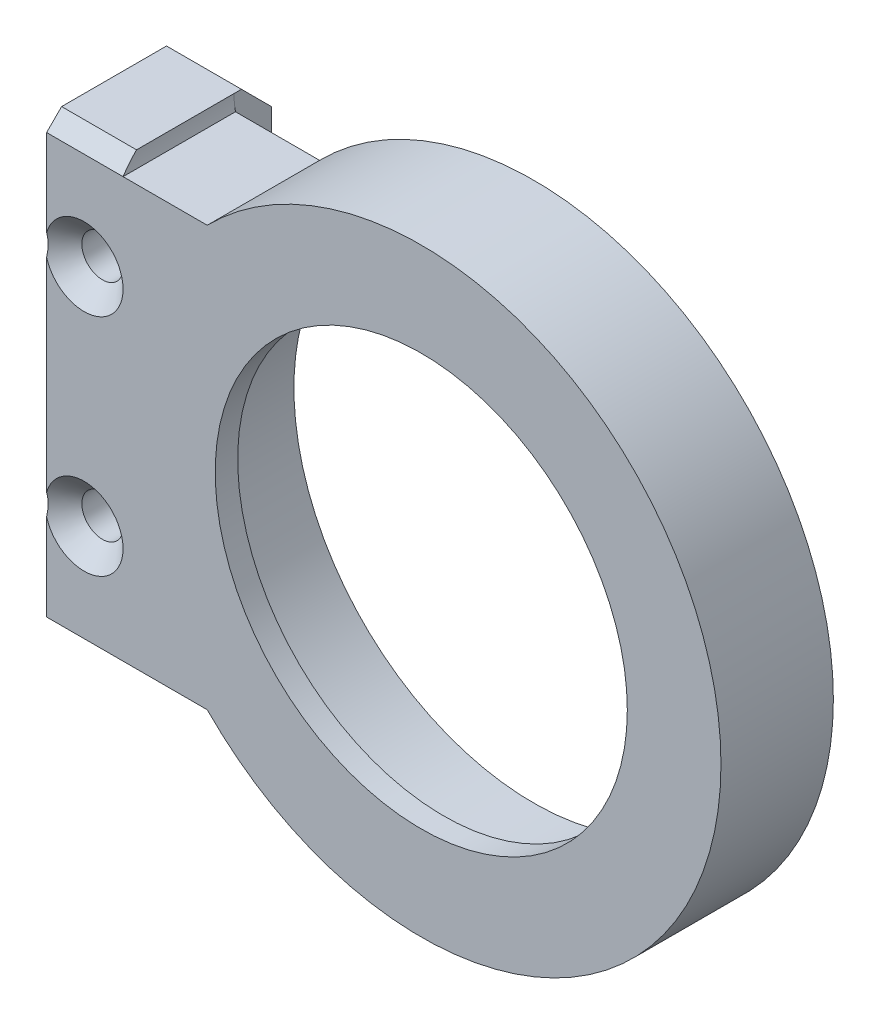
from build123d import *

# Parameters (mm, degrees)
SKETCH1_W                                       = 80
SKETCH1_H                                       = 80
BOSS_EXTRUDE1_DEPTH                             = 15
SKETCH2_R                                       = 32
CUT_EXTRUDE2_DEPTH                              = 16
SKETCH3_R                                       = 32
SKETCH3_R_2                                     = 27.5
BOSS_EXTRUDE2_DEPTH                             = 3
FILLET1_R                                       = 10
SKETCH5_W                                       = 10
SKETCH5_H                                       = 60
BOSS_EXTRUDE3_DEPTH                             = 20
SKETCH6_R                                       = 2.5
CUT_EXTRUDE3_DEPTH                              = 21
CHAMFER1_SIZE                                   = 2
CSK_FOR_M5_FLAT_HEAD_MACHINE_SCREW2_D           = 5.5
CSK_FOR_M5_FLAT_HEAD_MACHINE_SCREW2_CSINK_D     = 10.4
CSK_FOR_M5_FLAT_HEAD_MACHINE_SCREW2_CSINK_ANGLE = 90
CHAMFER2_SIZE                                   = 4
SKETCH11_R                                      = 15
CUT_EXTRUDE4_DEPTH                              = 2
CUT_EXTRUDE7_DEPTH                              = 21


with BuildPart() as part:
    # Sketch1 → Boss-Extrude1 (new body)
    with BuildSketch(Plane.XY):
        with Locations((40, 40)):
            Rectangle(SKETCH1_W, SKETCH1_H)
    extrude(amount=BOSS_EXTRUDE1_DEPTH)

    # Sketch2 → Cut-Extrude2 (cut, through all)
    with BuildSketch(Plane.XY.offset(15)):
        with Locations((40, 40)):
            Circle(SKETCH2_R)
    extrude(amount=-CUT_EXTRUDE2_DEPTH, mode=Mode.SUBTRACT)

    # Sketch3 → Boss-Extrude2 (add)
    with BuildSketch(Plane.XY.offset(15)):
        with Locations((40, 40)):
            Circle(SKETCH3_R)
        with Locations((40, 40)):
            Circle(SKETCH3_R_2, mode=Mode.SUBTRACT)
    extrude(amount=-BOSS_EXTRUDE2_DEPTH)

    # Fillet1
    fillet1_edges = [part.edges().sort_by_distance(p)[0] for p in [
        (0, 80, 7.5),
        (80, 80, 7.5),
        (80, 0, 7.5),
        (0, 0, 7.5),
    ]]
    fillet(fillet1_edges, radius=FILLET1_R)

    # Sketch5 → Boss-Extrude3 (add)
    with BuildSketch(Plane.XY.offset(15)):
        with Locations((-5, 40)):
            Rectangle(SKETCH5_W, SKETCH5_H)
    extrude(amount=-BOSS_EXTRUDE3_DEPTH)

    # Sketch6 → Cut-Extrude3 (cut, through all)
    with BuildSketch(Plane.XY.offset(15)):
        with Locations((-5, 55)):
            Circle(SKETCH6_R)
        with Locations((-5, 25)):
            Circle(SKETCH6_R)
    extrude(amount=-CUT_EXTRUDE3_DEPTH, mode=Mode.SUBTRACT)

    # Chamfer1
    chamfer1_edges = [part.edges().sort_by_distance(p)[0] for p in [
        (-5, 70, 15),
        (-5, 10, 15),
    ]]
    chamfer(chamfer1_edges, length=CHAMFER1_SIZE)

    # CSK for M5 Flat Head Machine Screw2 (through all)
    with Locations(Plane.XY.offset(15)):
        with Locations((-5, 55), (-5, 25)):
            CounterSinkHole(CSK_FOR_M5_FLAT_HEAD_MACHINE_SCREW2_D / 2, CSK_FOR_M5_FLAT_HEAD_MACHINE_SCREW2_CSINK_D / 2, counter_sink_angle=CSK_FOR_M5_FLAT_HEAD_MACHINE_SCREW2_CSINK_ANGLE)

    # Chamfer2
    chamfer2_edges = [part.edges().sort_by_distance(p)[0] for p in [
        (-5, 10, -5),
        (-5, 70, -5),
    ]]
    chamfer(chamfer2_edges, length=CHAMFER2_SIZE)

    # Sketch11 → Cut-Extrude4 (cut)
    with BuildSketch(Plane.ZY.offset(10)):
        with Locations((-15, 40)):
            Circle(SKETCH11_R)
    extrude(amount=-CUT_EXTRUDE4_DEPTH, mode=Mode.SUBTRACT)

    # Sketch12 → Cut-Extrude7 (cut, through all)
    with BuildSketch(Plane.XY.offset(15)):
        with BuildLine():
            Line((11.434286286, 12), (0.202041029, 12))
            ThreePointArc((0.202041029, 12), (0.05063847, 11.00508962), (0, 10))
            ThreePointArc((0, 10), (2.928932188, 2.928932188), (10, 0))
            Line((10, 0), (40, 0))
            ThreePointArc((40, 0), (24.508066615, 3.121822171), (11.434286286, 12))
        make_face()
        with BuildLine():
            ThreePointArc((80, 40), (68.284271247, 11.715728753), (40, 0))
            Line((40, 0), (70, 0))
            ThreePointArc((70, 0), (77.071067812, 2.928932188), (80, 10))
            Line((80, 10), (80, 40))
        make_face()
        with BuildLine():
            ThreePointArc((40.000000226, 80), (68.284271327, 68.284271168), (80, 40))
            Line((80, 40), (80, 70))
            ThreePointArc((80, 70), (77.071067812, 77.071067812), (70, 80))
            Line((70, 80), (40.000000226, 80))
        make_face()
        with BuildLine():
            ThreePointArc((11.434286286, 68), (24.508066719, 76.878177873), (40.000000226, 80))
            Line((40.000000226, 80), (10, 80))
            ThreePointArc((10, 80), (2.928932174, 77.071067798), (0, 69.99999996))
            ThreePointArc((0, 69.99999996), (0.050638472, 68.99491036), (0.202041029, 68))
            Line((0.202041029, 68), (11.434286286, 68))
        make_face()
    extrude(amount=-CUT_EXTRUDE7_DEPTH, mode=Mode.SUBTRACT)


solid = part.part
